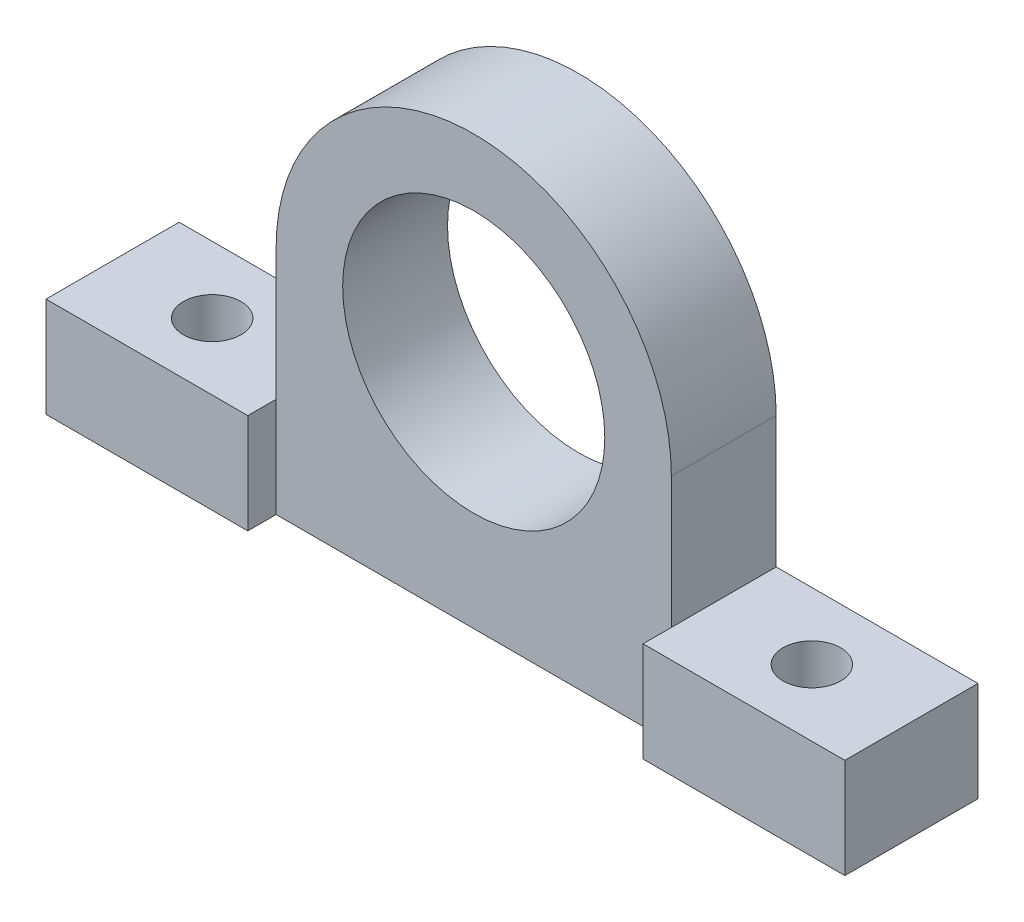
from build123d import *

# Parameters (mm, degrees)
SKETCH1_R             = 25
BOSS_EXTRUDE1_DEPTH   = 20
SKETCH2_W             = 38.5
SKETCH2_H             = 19.05
BOSS_EXTRUDE2_DEPTH   = 5.4
M10_CLEARANCE_HOLE1_D = 11


with BuildPart() as part:
    # Sketch1 → Boss-Extrude1 (new body)
    with BuildSketch(Plane.XY):
        with BuildLine():
            Line((-76.2, -25), (-76.2, -44.05))
            Line((-76.2, -44.05), (76.2, -44.05))
            Line((76.2, -44.05), (76.2, -25))
            Line((76.2, -25), (37.7, -25))
            Line((37.7, -25), (37.7, 0))
            ThreePointArc((37.7, 0), (0, 37.7), (-37.7, 0))
            Line((-37.7, 0), (-37.7, -25))
            Line((-37.7, -25), (-76.2, -25))
        make_face()
        Circle(SKETCH1_R, mode=Mode.SUBTRACT)
    extrude(amount=BOSS_EXTRUDE1_DEPTH)

    # Sketch2 → Boss-Extrude2 (add)
    with BuildSketch(Plane.XY.offset(20)):
        with Locations((-56.95, -34.525)):
            Rectangle(SKETCH2_W, SKETCH2_H)
        with Locations((56.95, -34.525)):
            Rectangle(SKETCH2_W, SKETCH2_H)
    extrude(amount=BOSS_EXTRUDE2_DEPTH)

    # M10 Clearance Hole1 (through all)
    with Locations(Plane(origin=(0, -25, 0), x_dir=(1, 0, 0), z_dir=(0, 1, 0))):
        with Locations((-57.2, -12.7), (57.2, -12.7)):
            Hole(M10_CLEARANCE_HOLE1_D / 2)


solid = part.part
